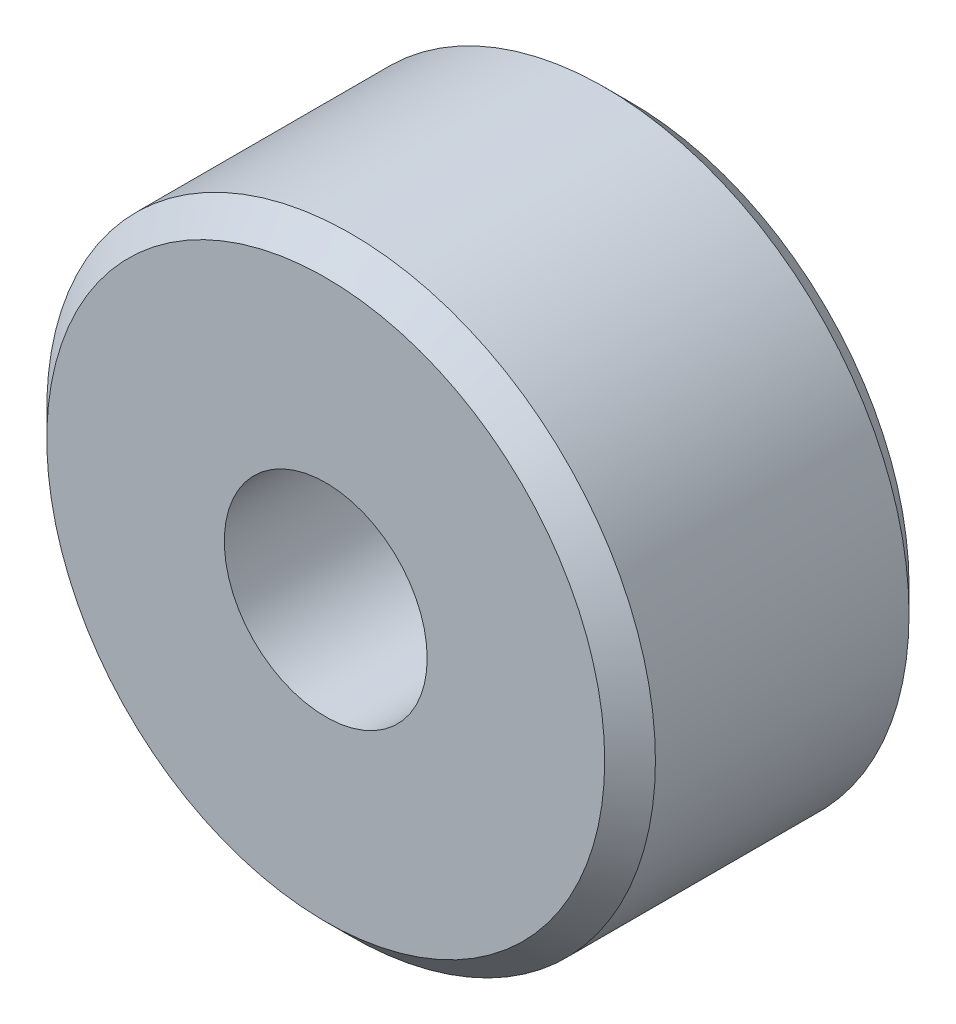
from build123d import *

# Parameters (mm, degrees)
SKETCH1_R           = 3
SKETCH1_R_2         = 1
EXTRUDE_THIN1_DEPTH = 3
CHAMFER1_SIZE       = 0.25


with BuildPart() as part:
    # Sketch1 → Extrude-Thin1 (new body)
    with BuildSketch(Plane.XY):
        Circle(SKETCH1_R)
        Circle(SKETCH1_R_2, mode=Mode.SUBTRACT)
    extrude(amount=EXTRUDE_THIN1_DEPTH)

    # Chamfer1
    chamfer1_edges = [part.edges().sort_by_distance(p)[0] for p in [
        (-3, 0, 0),
        (-3, 0, 3),
    ]]
    chamfer(chamfer1_edges, length=CHAMFER1_SIZE)


solid = part.part
